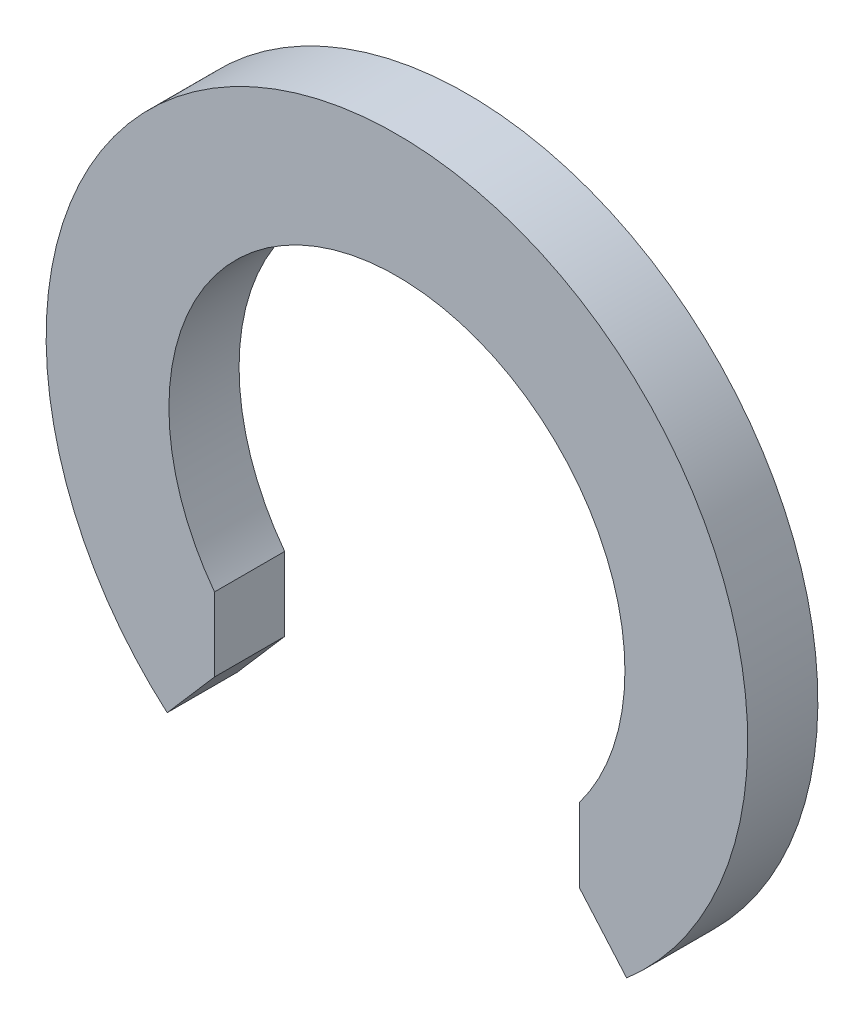
from build123d import *

# Parameters (mm, degrees)
CROQUIS1_R              = 5
CROQUIS1_R_2            = 3.25
SALIENTE_EXTRUIR1_DEPTH = 1
CORTAR_EXTRUIR1_DEPTH   = 10


with BuildPart() as part:
    # Croquis1 → Saliente-Extruir1 (new body)
    with BuildSketch(Plane.XY):
        Circle(CROQUIS1_R)
        Circle(CROQUIS1_R_2, mode=Mode.SUBTRACT)
    extrude(amount=SALIENTE_EXTRUIR1_DEPTH)

    # Croquis2 → Cortar-Extruir1 (cut)
    with BuildSketch(Plane.XY.offset(1)):
        Polygon((-2.6, -3), (-3.274652692, -3.778445414), (-3.274652692, -6), (-2.6, -6), (2.6, -6), (3.274652692, -6), (3.274652692, -3.778445414), (2.6, -3), (2.6, 0), (-2.6, 0), align=None)
    extrude(amount=-CORTAR_EXTRUIR1_DEPTH, mode=Mode.SUBTRACT)


solid = part.part
